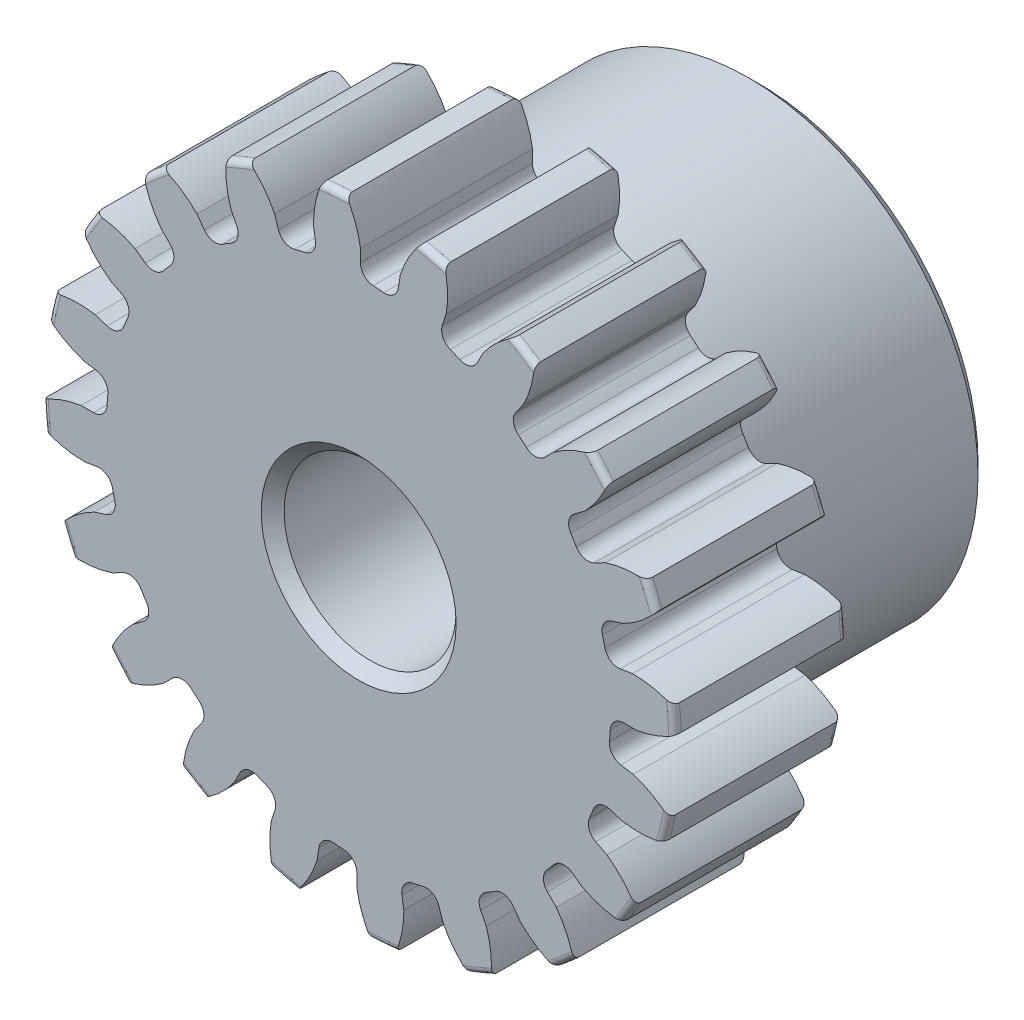
from build123d import *

# Parameters (mm, degrees)
SKETCH1_R                = 8.763
BOSS_EXTRUDE1_DEPTH      = 4.7625
SKETCH2_W                = 6.35
SKETCH2_H                = 6.35
FILLET2_R                = 0.17526
CUT_EXTRUDE1_DEPTH       = 12.1125
FILLET1_R                = 0.37404675
CIRPATTERN1_COUNT        = 20
FILLET1_OF_CIRPATTERN1_R = 0.37404675
SKETCH5_R                = 2.38125
CUT_EXTRUDE2_DEPTH       = 12.1125
CHAMFER1_SIZE            = 0.3175


with BuildPart() as part:
    # Sketch1 → Boss-Extrude1 (new body)
    with BuildSketch(Plane.XY):
        Circle(SKETCH1_R)
    extrude(amount=-BOSS_EXTRUDE1_DEPTH)

    # Sketch2 → Revolve1 (revolve)
    with BuildSketch(Plane(origin=(0, 0, 0), x_dir=(0, 0, -1), z_dir=(1, 0, 0))):
        with Locations((7.9375, 3.175)):
            Rectangle(SKETCH2_W, SKETCH2_H)
    revolve(axis=Axis((0, 0, -4.7625), (0, 0, -1)))

    # Fillet2
    fillet2_edges = [part.edges().sort_by_distance(p)[0] for p in [
        (-8.763, 0, 0),
        (-8.763, 0, -4.7625),
        (0, -6.35, -4.7625),
    ]]
    fillet(fillet2_edges, radius=FILLET2_R)

    # Sketch4 → Cut-Extrude1 (cut, through all)
    with BuildSketch(Plane.XY):
        with BuildLine():
            Line((0.049773211, 7.684510705), (0.049773211, 6.976884961))
            ThreePointArc((0.049773211, 6.976884961), (0.547415292, 6.955554444), (1.04226738, 6.898773792))
            Line((1.04226738, 6.898773792), (1.152964691, 7.597687448))
            add(Edge.make_bspline(
                [(2.246873251, 9.084452986), (1.433305224, 8.484100067), (1.152964691, 7.597687448)],
                knots=[0, 0, 0, 1, 1, 1], degree=2))
            ThreePointArc((2.246873251, 9.084452986), (0.734236861, 9.329341976), (-0.798085545, 9.324097003))
            add(Edge.make_bspline(
                [(-0.798085545, 9.324097003), (-0.088450043, 8.603865085), (0.049773211, 7.684510705)],
                knots=[0, 0, 0, 1, 1, 1], degree=2))
        make_face()
    cut_extrude1 = extrude(amount=-CUT_EXTRUDE1_DEPTH, mode=Mode.SUBTRACT)

    # Fillet1
    fillet1_edges = [part.edges().sort_by_distance(p)[0] for p in [
        (1.04226738, 6.898773792, -2.38125),
        (0.049773211, 6.976884961, -2.38125),
    ]]
    fillet(fillet1_edges, radius=FILLET1_R)

    # CirPattern1: Cut-Extrude1 ×20 about axis
    cirpattern1_axis = Axis((0, 0, -4.7625), (0, 0, 1))
    for i in range(1, CIRPATTERN1_COUNT):
        add(cut_extrude1.rotate(cirpattern1_axis, i * 360 / CIRPATTERN1_COUNT), mode=Mode.SUBTRACT)

    # Fillet1 of CirPattern1
    fillet1_of_cirpattern1_edges = [part.edges().sort_by_distance(p)[0] for p in [
        (-1.140583159, 6.883202103, -2.38125),
        (-2.108638884, 6.650792674, -2.38125),
        (-3.211785471, 6.193854633, -2.38125),
        (-4.060642713, 5.673674461, -2.38125),
        (-4.968595843, 4.898209517, -2.38125),
        (-5.615162541, 4.141177461, -2.38125),
        (-6.239045437, 3.123093526, -2.38125),
        (-6.620031137, 2.203313158, -2.38125),
        (-6.898773792, 1.04226738, -2.38125),
        (-6.976884961, 0.049773211, -2.38125),
        (-6.883202103, -1.140583159, -2.38125),
        (-6.650792674, -2.108638884, -2.38125),
        (-6.193854633, -3.211785471, -2.38125),
        (-5.673674461, -4.060642713, -2.38125),
        (-4.898209517, -4.968595843, -2.38125),
        (-4.141177461, -5.615162541, -2.38125),
        (-3.123093526, -6.239045437, -2.38125),
        (-2.203313158, -6.620031137, -2.38125),
        (-1.04226738, -6.898773792, -2.38125),
        (-0.049773211, -6.976884961, -2.38125),
        (1.140583159, -6.883202103, -2.38125),
        (2.108638884, -6.650792674, -2.38125),
        (3.211785471, -6.193854633, -2.38125),
        (4.060642713, -5.673674461, -2.38125),
        (4.968595843, -4.898209517, -2.38125),
        (5.615162541, -4.141177461, -2.38125),
        (6.239045437, -3.123093526, -2.38125),
        (6.620031137, -2.203313158, -2.38125),
        (6.898773792, -1.04226738, -2.38125),
        (6.976884961, -0.049773211, -2.38125),
        (6.883202103, 1.140583159, -2.38125),
        (6.650792674, 2.108638884, -2.38125),
        (6.193854633, 3.211785471, -2.38125),
        (5.673674461, 4.060642713, -2.38125),
        (4.898209517, 4.968595843, -2.38125),
        (4.141177461, 5.615162541, -2.38125),
        (3.123093526, 6.239045437, -2.38125),
        (2.203313158, 6.620031137, -2.38125),
    ]]
    fillet(fillet1_of_cirpattern1_edges, radius=FILLET1_OF_CIRPATTERN1_R)

    # Sketch5 → Cut-Extrude2 (cut, through all)
    with BuildSketch(Plane.XY):
        Circle(SKETCH5_R)
    extrude(amount=-CUT_EXTRUDE2_DEPTH, mode=Mode.SUBTRACT)

    # Chamfer1
    chamfer1_edges = [part.edges().sort_by_distance(p)[0] for p in [
        (0, -6.35, -11.1125),
        (-2.38125, 0, -11.1125),
        (-2.38125, 0, 0),
    ]]
    chamfer(chamfer1_edges, length=CHAMFER1_SIZE)


solid = part.part
